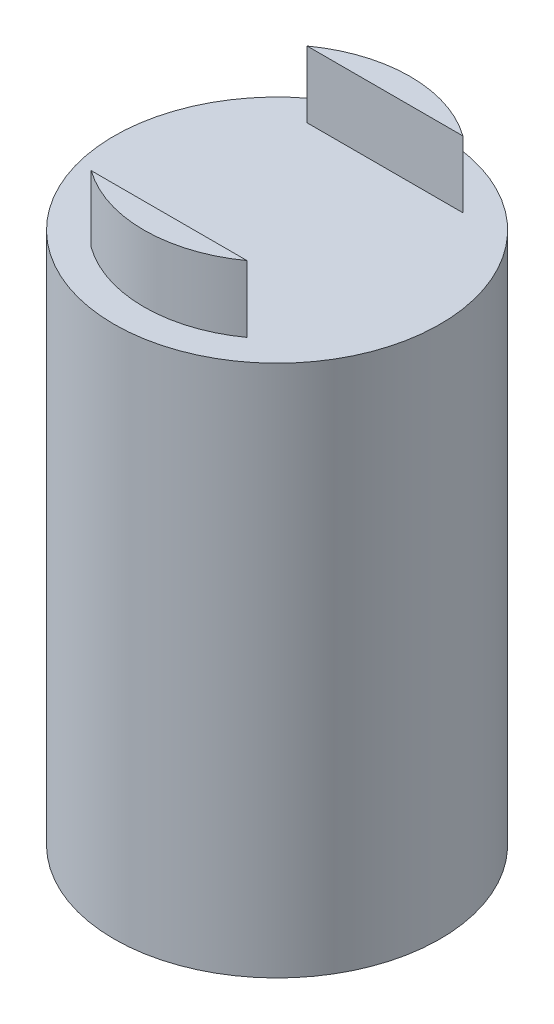
from build123d import *

# Parameters (mm, degrees)
SKETCH1_R           = 31.115
BOSS_EXTRUDE4_DEPTH = 101.6
BOSS_EXTRUDE6_DEPTH = 12.7


with BuildPart() as part:
    # Sketch1 → Boss-Extrude4 (new body)
    with BuildSketch(Plane(origin=(0, 0, 0), x_dir=(1, 0, 0), z_dir=(0, 1, 0))):
        Circle(SKETCH1_R)
    extrude(amount=BOSS_EXTRUDE4_DEPTH)

    # Sketch4 → Boss-Extrude6 (add)
    with BuildSketch(Plane(origin=(0, 101.6, 0), x_dir=(1, 0, 0), z_dir=(0, 1, 0))):
        with BuildLine():
            ThreePointArc((14.859, 20.600245605), (0, 25.4), (-14.859, 20.600245605))
            Line((-14.859, 20.600245605), (14.859, 20.600245605))
        make_face()
        with BuildLine():
            Line((14.859, -20.600245605), (-14.859, -20.600245605))
            ThreePointArc((-14.859, -20.600245605), (0, -25.4), (14.859, -20.600245605))
        make_face()
    extrude(amount=BOSS_EXTRUDE6_DEPTH)


solid = part.part
